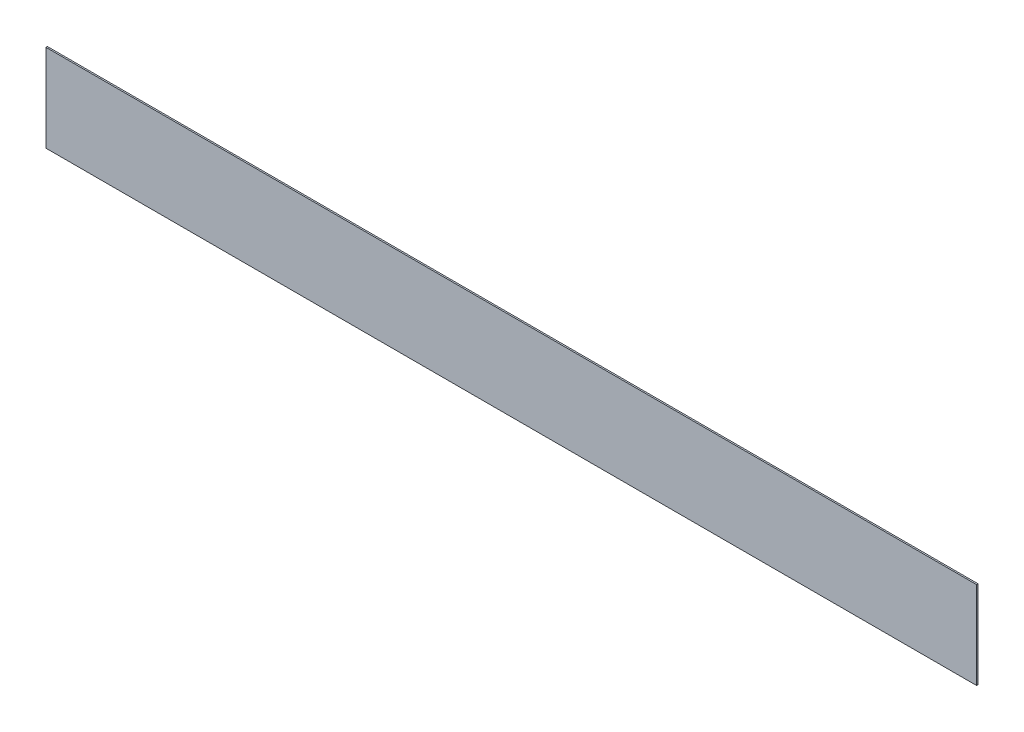
from build123d import *

# Parameters (mm, degrees)
ESQUISSE1_W        = 1278
ESQUISSE1_H        = 120
BOSS_EXTRU_1_DEPTH = 2


with BuildPart() as part:
    # Esquisse1 → Boss.-Extru.1 (new body)
    with BuildSketch(Plane.XY):
        with Locations((639, 60)):
            Rectangle(ESQUISSE1_W, ESQUISSE1_H)
    extrude(amount=BOSS_EXTRU_1_DEPTH)


solid = part.part
